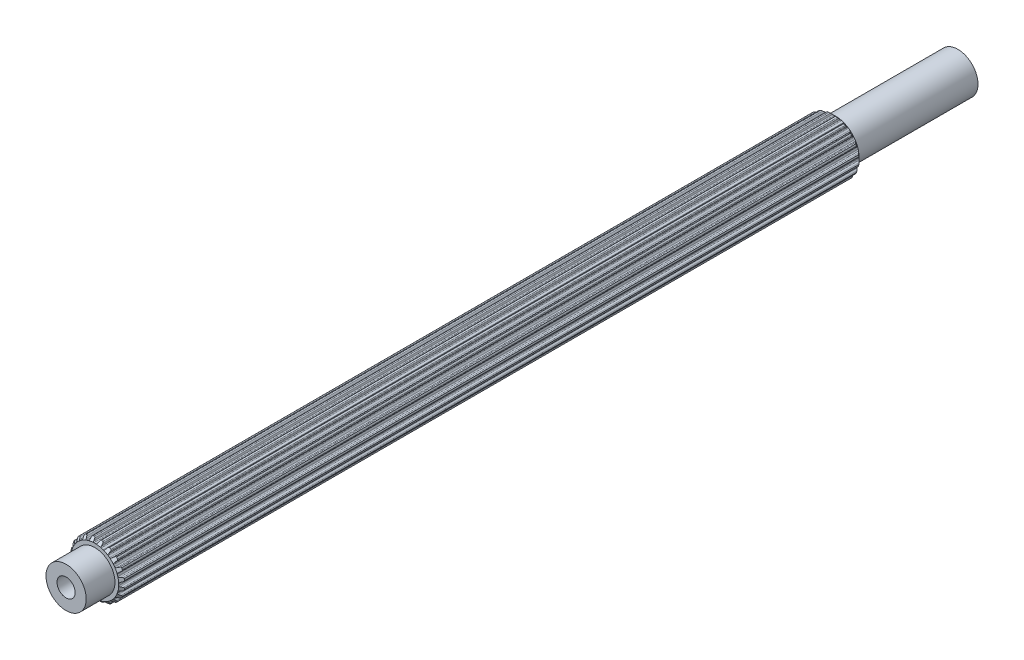
from build123d import *

# Parameters (mm, degrees)
BOSS_EXTRUDE1_DEPTH            = 46.04766
SKETCH2_R                      = 2.5019
BOSS_EXTRUDE2_DEPTH            = 49.62906
BOSS_EXTRUDE2_DEPTH_BACK       = 61.31306
CUT_EXTRUDE1_REACH             = 51.629
SKETCH7_R                      = 1.1303
CUT_EXTRUDE1_DIRECTION_2_REACH = 63.313
SKETCH8_R                      = 1.1303
BOSS_EXTRUDE3_DEPTH            = 40.10406
BOSS_EXTRUDE3_DEPTH_BACK       = 51.78806


with BuildPart() as part:
    # Sketch1 → Boss-Extrude1 (new body, symmetric)
    with BuildSketch(Plane.XY):
        with BuildLine():
            Line((-0.106949245, 2.969874934), (0.106949245, 2.969874934))
            ThreePointArc((0.106949245, 2.969874934), (0.196343213, 2.986924176), (0.253739238, 3.057547504))
            Line((0.253739238, 3.057547504), (0.315888147, 3.237526941))
            ThreePointArc((0.315888147, 3.237526941), (0.359032156, 3.298322911), (0.4281449, 3.326269005))
            Line((0.4281449, 3.326269005), (0.620027588, 3.2937547))
            ThreePointArc((0.620027588, 3.2937547), (0.689621142, 3.24802576), (0.718272212, 3.169836791))
            Line((0.718272212, 3.169836791), (0.724389167, 2.979527391))
            ThreePointArc((0.724389167, 2.979527391), (0.750934762, 2.9040661), (0.816027049, 2.857568043))
            Line((0.816027049, 2.857568043), (1.019456602, 2.791469774))
            ThreePointArc((1.019456602, 2.791469774), (1.109743823, 2.780060312), (1.186154496, 2.829490741))
            Line((1.186154496, 2.829490741), (1.300878326, 2.981456288))
            ThreePointArc((1.300878326, 2.981456288), (1.360697704, 3.02594446), (1.435063648, 3.031165762))
            Line((1.435063648, 3.031165762), (1.607507455, 2.940947809))
            ThreePointArc((1.607507455, 2.940947809), (1.659563839, 2.875951412), (1.662650905, 2.792735615))
            Line((1.662650905, 2.792735615), (1.609659636, 2.609850378))
            ThreePointArc((1.609659636, 2.609850378), (1.611587176, 2.529879385), (1.659124931, 2.465542482))
            Line((1.659124931, 2.465542482), (1.832172444, 2.339816104))
            ThreePointArc((1.832172444, 2.339816104), (1.914514976, 2.301064775), (2.002460687, 2.32446371))
            Line((2.002460687, 2.32446371), (2.158529469, 2.433539921))
            ThreePointArc((2.158529469, 2.433539921), (2.229168681, 2.457365482), (2.301508367, 2.439350895))
            Line((2.301508367, 2.439350895), (2.437633293, 2.300260456))
            ThreePointArc((2.437633293, 2.300260456), (2.467056864, 2.222358901), (2.444277744, 2.14226202))
            Line((2.444277744, 2.14226202), (2.337365406, 1.984703026))
            ThreePointArc((2.337365406, 1.984703026), (2.314486209, 1.908050449), (2.339816104, 1.832172444))
            Line((2.339816104, 1.832172444), (2.465542482, 1.659124931))
            ThreePointArc((2.465542482, 1.659124931), (2.531880064, 1.596824985), (2.622752074, 1.591901975))
            Line((2.622752074, 1.591901975), (2.804888709, 1.64741171))
            ThreePointArc((2.804888709, 1.64741171), (2.879433095, 1.648242449), (2.942665411, 1.608755366))
            Line((2.942665411, 1.608755366), (3.0291466, 1.434407582))
            ThreePointArc((3.0291466, 1.434407582), (3.033057175, 1.351226417), (2.986641646, 1.282088892))
            Line((2.986641646, 1.282088892), (2.836273564, 1.165279113))
            ThreePointArc((2.836273564, 1.165279113), (2.790827206, 1.099448241), (2.791469774, 1.019456602))
            Line((2.791469774, 1.019456602), (2.857568043, 0.816027049))
            ThreePointArc((2.857568043, 0.816027049), (2.901407091, 0.736276839), (2.986310214, 0.703513784))
            Line((2.986310214, 0.703513784), (3.1766859, 0.700023363))
            ThreePointArc((3.1766859, 0.700023363), (3.247838536, 0.677777961), (3.295773863, 0.620683653))
            Line((3.295773863, 0.620683653), (3.324145932, 0.4281449))
            ThreePointArc((3.324145932, 0.4281449), (3.302160717, 0.347826477), (3.236652255, 0.29641597))
            Line((3.236652255, 0.29641597), (3.057547504, 0.231789562))
            ThreePointArc((3.057547504, 0.231789562), (2.993982591, 0.183224379), (2.969874934, 0.106949245))
            Line((2.969874934, 0.106949245), (2.969874934, -0.106949245))
            ThreePointArc((2.969874934, -0.106949245), (2.986924176, -0.196343213), (3.057547504, -0.253739238))
            Line((3.057547504, -0.253739238), (3.237526941, -0.315888147))
            ThreePointArc((3.237526941, -0.315888147), (3.298322911, -0.359032156), (3.326269005, -0.4281449))
            Line((3.326269005, -0.4281449), (3.2937547, -0.620027588))
            ThreePointArc((3.2937547, -0.620027588), (3.24802576, -0.689621142), (3.169836791, -0.718272212))
            Line((3.169836791, -0.718272212), (2.979527391, -0.724389167))
            ThreePointArc((2.979527391, -0.724389167), (2.9040661, -0.750934762), (2.857568043, -0.816027049))
            Line((2.857568043, -0.816027049), (2.791469774, -1.019456602))
            ThreePointArc((2.791469774, -1.019456602), (2.780060312, -1.109743823), (2.829490741, -1.186154496))
            Line((2.829490741, -1.186154496), (2.981456288, -1.300878326))
            ThreePointArc((2.981456288, -1.300878326), (3.02594446, -1.360697704), (3.031165762, -1.435063648))
            Line((3.031165762, -1.435063648), (2.940947809, -1.607507455))
            ThreePointArc((2.940947809, -1.607507455), (2.875951412, -1.659563839), (2.792735615, -1.662650905))
            Line((2.792735615, -1.662650905), (2.609850378, -1.609659636))
            ThreePointArc((2.609850378, -1.609659636), (2.529879385, -1.611587176), (2.465542482, -1.659124931))
            Line((2.465542482, -1.659124931), (2.339816104, -1.832172444))
            ThreePointArc((2.339816104, -1.832172444), (2.301064775, -1.914514976), (2.32446371, -2.002460687))
            Line((2.32446371, -2.002460687), (2.433539921, -2.158529469))
            ThreePointArc((2.433539921, -2.158529469), (2.457365482, -2.229168681), (2.439350895, -2.301508367))
            Line((2.439350895, -2.301508367), (2.300260456, -2.437633293))
            ThreePointArc((2.300260456, -2.437633293), (2.222358901, -2.467056864), (2.14226202, -2.444277744))
            Line((2.14226202, -2.444277744), (1.984703026, -2.337365406))
            ThreePointArc((1.984703026, -2.337365406), (1.908050449, -2.314486209), (1.832172444, -2.339816104))
            Line((1.832172444, -2.339816104), (1.659124931, -2.465542482))
            ThreePointArc((1.659124931, -2.465542482), (1.596824985, -2.531880064), (1.591901975, -2.622752074))
            Line((1.591901975, -2.622752074), (1.64741171, -2.804888709))
            ThreePointArc((1.64741171, -2.804888709), (1.648242449, -2.879433095), (1.608755366, -2.942665411))
            Line((1.608755366, -2.942665411), (1.434407582, -3.0291466))
            ThreePointArc((1.434407582, -3.0291466), (1.351226417, -3.033057175), (1.282088892, -2.986641646))
            Line((1.282088892, -2.986641646), (1.165279113, -2.836273564))
            ThreePointArc((1.165279113, -2.836273564), (1.099448241, -2.790827206), (1.019456602, -2.791469774))
            Line((1.019456602, -2.791469774), (0.816027049, -2.857568043))
            ThreePointArc((0.816027049, -2.857568043), (0.736276839, -2.901407091), (0.703513784, -2.986310214))
            Line((0.703513784, -2.986310214), (0.700023363, -3.1766859))
            ThreePointArc((0.700023363, -3.1766859), (0.677777961, -3.247838536), (0.620683653, -3.295773863))
            Line((0.620683653, -3.295773863), (0.4281449, -3.324145932))
            ThreePointArc((0.4281449, -3.324145932), (0.347826477, -3.302160717), (0.29641597, -3.236652255))
            Line((0.29641597, -3.236652255), (0.231789562, -3.057547504))
            ThreePointArc((0.231789562, -3.057547504), (0.183224379, -2.993982591), (0.106949245, -2.969874934))
            Line((0.106949245, -2.969874934), (-0.106949245, -2.969874934))
            ThreePointArc((-0.106949245, -2.969874934), (-0.196343213, -2.986924176), (-0.253739238, -3.057547504))
            Line((-0.253739238, -3.057547504), (-0.315888147, -3.237526941))
            ThreePointArc((-0.315888147, -3.237526941), (-0.359032156, -3.298322911), (-0.4281449, -3.326269005))
            Line((-0.4281449, -3.326269005), (-0.620027588, -3.2937547))
            ThreePointArc((-0.620027588, -3.2937547), (-0.689621142, -3.24802576), (-0.718272212, -3.169836791))
            Line((-0.718272212, -3.169836791), (-0.724389167, -2.979527391))
            ThreePointArc((-0.724389167, -2.979527391), (-0.750934762, -2.9040661), (-0.816027049, -2.857568043))
            Line((-0.816027049, -2.857568043), (-1.019456602, -2.791469774))
            ThreePointArc((-1.019456602, -2.791469774), (-1.109743823, -2.780060312), (-1.186154496, -2.829490741))
            Line((-1.186154496, -2.829490741), (-1.300878326, -2.981456288))
            ThreePointArc((-1.300878326, -2.981456288), (-1.360697704, -3.02594446), (-1.435063648, -3.031165762))
            Line((-1.435063648, -3.031165762), (-1.607507455, -2.940947809))
            ThreePointArc((-1.607507455, -2.940947809), (-1.659563839, -2.875951412), (-1.662650905, -2.792735615))
            Line((-1.662650905, -2.792735615), (-1.609659636, -2.609850378))
            ThreePointArc((-1.609659636, -2.609850378), (-1.611587176, -2.529879385), (-1.659124931, -2.465542482))
            Line((-1.659124931, -2.465542482), (-1.832172444, -2.339816104))
            ThreePointArc((-1.832172444, -2.339816104), (-1.914514976, -2.301064775), (-2.002460687, -2.32446371))
            Line((-2.002460687, -2.32446371), (-2.158529469, -2.433539921))
            ThreePointArc((-2.158529469, -2.433539921), (-2.229168681, -2.457365482), (-2.301508367, -2.439350895))
            Line((-2.301508367, -2.439350895), (-2.437633293, -2.300260456))
            ThreePointArc((-2.437633293, -2.300260456), (-2.467056864, -2.222358901), (-2.444277744, -2.14226202))
            Line((-2.444277744, -2.14226202), (-2.337365406, -1.984703026))
            ThreePointArc((-2.337365406, -1.984703026), (-2.314486209, -1.908050449), (-2.339816104, -1.832172444))
            Line((-2.339816104, -1.832172444), (-2.465542482, -1.659124931))
            ThreePointArc((-2.465542482, -1.659124931), (-2.531880064, -1.596824985), (-2.622752074, -1.591901975))
            Line((-2.622752074, -1.591901975), (-2.804888709, -1.64741171))
            ThreePointArc((-2.804888709, -1.64741171), (-2.879433095, -1.648242449), (-2.942665411, -1.608755366))
            Line((-2.942665411, -1.608755366), (-3.0291466, -1.434407582))
            ThreePointArc((-3.0291466, -1.434407582), (-3.033057175, -1.351226417), (-2.986641646, -1.282088892))
            Line((-2.986641646, -1.282088892), (-2.836273564, -1.165279113))
            ThreePointArc((-2.836273564, -1.165279113), (-2.790827206, -1.099448241), (-2.791469774, -1.019456602))
            Line((-2.791469774, -1.019456602), (-2.857568043, -0.816027049))
            ThreePointArc((-2.857568043, -0.816027049), (-2.901407091, -0.736276839), (-2.986310214, -0.703513784))
            Line((-2.986310214, -0.703513784), (-3.1766859, -0.700023363))
            ThreePointArc((-3.1766859, -0.700023363), (-3.247838536, -0.677777961), (-3.295773863, -0.620683653))
            Line((-3.295773863, -0.620683653), (-3.324145932, -0.4281449))
            ThreePointArc((-3.324145932, -0.4281449), (-3.302160717, -0.347826477), (-3.236652255, -0.29641597))
            Line((-3.236652255, -0.29641597), (-3.057547504, -0.231789562))
            ThreePointArc((-3.057547504, -0.231789562), (-2.993982591, -0.183224379), (-2.969874934, -0.106949245))
            Line((-2.969874934, -0.106949245), (-2.969874934, 0.106949245))
            ThreePointArc((-2.969874934, 0.106949245), (-2.986924176, 0.196343213), (-3.057547504, 0.253739238))
            Line((-3.057547504, 0.253739238), (-3.237526941, 0.315888147))
            ThreePointArc((-3.237526941, 0.315888147), (-3.298322911, 0.359032156), (-3.326269005, 0.4281449))
            Line((-3.326269005, 0.4281449), (-3.2937547, 0.620027588))
            ThreePointArc((-3.2937547, 0.620027588), (-3.24802576, 0.689621142), (-3.169836791, 0.718272212))
            Line((-3.169836791, 0.718272212), (-2.979527391, 0.724389167))
            ThreePointArc((-2.979527391, 0.724389167), (-2.9040661, 0.750934762), (-2.857568043, 0.816027049))
            Line((-2.857568043, 0.816027049), (-2.791469774, 1.019456602))
            ThreePointArc((-2.791469774, 1.019456602), (-2.780060312, 1.109743823), (-2.829490741, 1.186154496))
            Line((-2.829490741, 1.186154496), (-2.981456288, 1.300878326))
            ThreePointArc((-2.981456288, 1.300878326), (-3.02594446, 1.360697704), (-3.031165762, 1.435063648))
            Line((-3.031165762, 1.435063648), (-2.940947809, 1.607507455))
            ThreePointArc((-2.940947809, 1.607507455), (-2.875951412, 1.659563839), (-2.792735615, 1.662650905))
            Line((-2.792735615, 1.662650905), (-2.609850378, 1.609659636))
            ThreePointArc((-2.609850378, 1.609659636), (-2.529879385, 1.611587176), (-2.465542482, 1.659124931))
            Line((-2.465542482, 1.659124931), (-2.339816104, 1.832172444))
            ThreePointArc((-2.339816104, 1.832172444), (-2.301064775, 1.914514976), (-2.32446371, 2.002460687))
            Line((-2.32446371, 2.002460687), (-2.433539921, 2.158529469))
            ThreePointArc((-2.433539921, 2.158529469), (-2.457365482, 2.229168681), (-2.439350895, 2.301508367))
            Line((-2.439350895, 2.301508367), (-2.300260456, 2.437633293))
            ThreePointArc((-2.300260456, 2.437633293), (-2.222358901, 2.467056864), (-2.14226202, 2.444277744))
            Line((-2.14226202, 2.444277744), (-1.984703026, 2.337365406))
            ThreePointArc((-1.984703026, 2.337365406), (-1.908050449, 2.314486209), (-1.832172444, 2.339816104))
            Line((-1.832172444, 2.339816104), (-1.659124931, 2.465542482))
            ThreePointArc((-1.659124931, 2.465542482), (-1.596824985, 2.531880064), (-1.591901975, 2.622752074))
            Line((-1.591901975, 2.622752074), (-1.64741171, 2.804888709))
            ThreePointArc((-1.64741171, 2.804888709), (-1.648242449, 2.879433095), (-1.608755366, 2.942665411))
            Line((-1.608755366, 2.942665411), (-1.434407582, 3.0291466))
            ThreePointArc((-1.434407582, 3.0291466), (-1.351226417, 3.033057175), (-1.282088892, 2.986641646))
            Line((-1.282088892, 2.986641646), (-1.165279113, 2.836273564))
            ThreePointArc((-1.165279113, 2.836273564), (-1.099448241, 2.790827206), (-1.019456602, 2.791469774))
            Line((-1.019456602, 2.791469774), (-0.816027049, 2.857568043))
            ThreePointArc((-0.816027049, 2.857568043), (-0.736276839, 2.901407091), (-0.703513784, 2.986310214))
            Line((-0.703513784, 2.986310214), (-0.700023363, 3.1766859))
            ThreePointArc((-0.700023363, 3.1766859), (-0.677777961, 3.247838536), (-0.620683653, 3.295773863))
            Line((-0.620683653, 3.295773863), (-0.4281449, 3.324145932))
            ThreePointArc((-0.4281449, 3.324145932), (-0.347826477, 3.302160717), (-0.29641597, 3.236652255))
            Line((-0.29641597, 3.236652255), (-0.231789562, 3.057547504))
            ThreePointArc((-0.231789562, 3.057547504), (-0.183224379, 2.993982591), (-0.106949245, 2.969874934))
        make_face()
    extrude(amount=BOSS_EXTRUDE1_DEPTH, both=True)

    # Sketch2 → Boss-Extrude2 (add, two sides)
    with BuildSketch(Plane.XY) as boss_extrude2_sk:
        Circle(SKETCH2_R)
    extrude(amount=BOSS_EXTRUDE2_DEPTH)
    extrude(boss_extrude2_sk.sketch, amount=-BOSS_EXTRUDE2_DEPTH_BACK)

    # Sketch3 → Cut-Revolve1 (revolve, cut)
    with BuildSketch(Plane(origin=(0, 0, 0), x_dir=(0, 0, -1), z_dir=(1, 0, 0))):
        Polygon((-44.916435505, 4.101099429), (-46.04766, 2.969874934), (-46.04766, 4.101099429), align=None)
        Polygon((46.04766, 42.761529155), (46.04766, 2.969874934), (26.151832889, 22.865702045), align=None)
    revolve(axis=Axis((0, 0, 14.360793934), (0, 0, -1)), mode=Mode.SUBTRACT)

    # Cut-Extrude1: up to this face of the body (flat: up to its plane)
    cut_extrude1_end = Plane(part.part.faces().sort_by_distance((0, 0, 49.62906))[0])
    # Sketch7 → Cut-Extrude1 (cut, up to the picked face)
    with BuildSketch(Plane.XY, mode=Mode.PRIVATE) as cut_extrude1_sk1:
        Circle(SKETCH7_R)
    cut_extrude1_tool1 = split(extrude(cut_extrude1_sk1.sketch, amount=CUT_EXTRUDE1_REACH, mode=Mode.PRIVATE), bisect_by=cut_extrude1_end, keep=Keep.BOTH, mode=Mode.PRIVATE)
    add(cut_extrude1_tool1.solids().sort_by_distance((0, 0, 0))[0], mode=Mode.SUBTRACT)

    # Cut-Extrude1 direction 2: up to this face of the body (flat: up to its plane)
    cut_extrude1_direction_2_end = Plane(part.part.faces().sort_by_distance((0, 0, -61.31306))[0])
    # Sketch7 → Cut-Extrude1 direction 2 (cut, up to the picked face)
    with BuildSketch(Plane.XY, mode=Mode.PRIVATE) as cut_extrude1_direction_2_sk1:
        Circle(SKETCH7_R)
    cut_extrude1_direction_2_tool1 = split(extrude(cut_extrude1_direction_2_sk1.sketch, amount=-CUT_EXTRUDE1_DIRECTION_2_REACH, mode=Mode.PRIVATE), bisect_by=cut_extrude1_direction_2_end, keep=Keep.BOTH, mode=Mode.PRIVATE)
    add(cut_extrude1_direction_2_tool1.solids().sort_by_distance((0, 0, 0))[0], mode=Mode.SUBTRACT)

    # Sketch8 → Boss-Extrude3 (add, two sides)
    with BuildSketch(Plane.XY) as boss_extrude3_sk:
        Circle(SKETCH8_R)
    extrude(amount=BOSS_EXTRUDE3_DEPTH)
    extrude(boss_extrude3_sk.sketch, amount=-BOSS_EXTRUDE3_DEPTH_BACK)


solid = part.part
